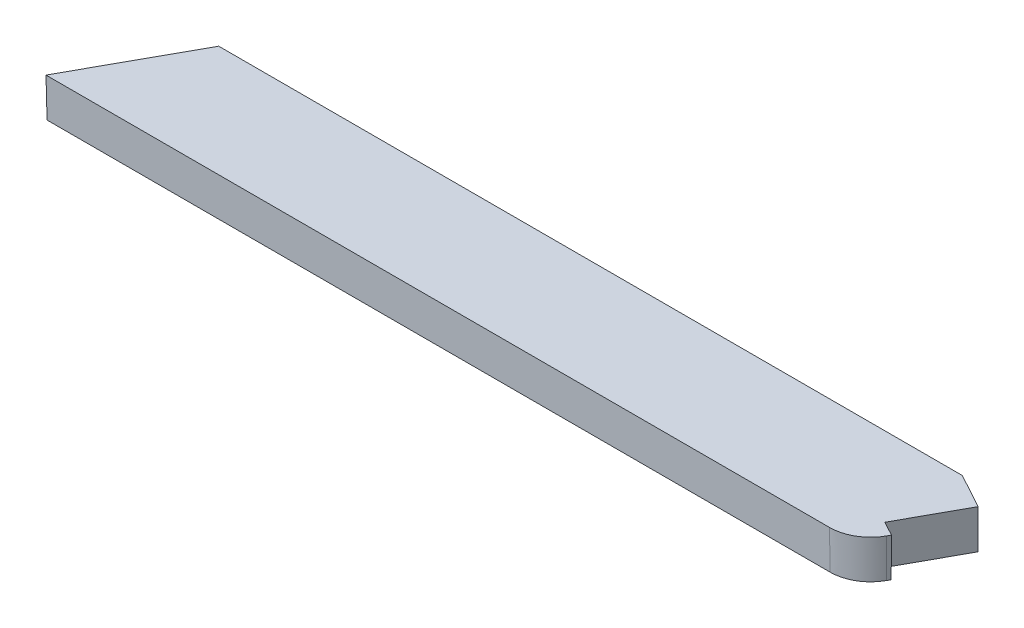
from build123d import *

# Parameters (mm, degrees)
BOSS_EXTRUDE1_DEPTH = 5
CUT_EXTRUDE1_REACH  = 114.056
CUT_EXTRUDE2_REACH  = 111.68
FILLET1_R           = 5.25
DRAFT1_ANGLE        = -1


with BuildPart() as part:
    # Sketch1 → Boss-Extrude1 (new body)
    with BuildSketch(Plane(origin=(0, 0, 0), x_dir=(1, 0, 0), z_dir=(0, 1, 0))):
        Polygon((0, 0), (7.835950564, 14.23), (111.035815461, 14.23), (103.199864898, 0), align=None)
    extrude(amount=BOSS_EXTRUDE1_DEPTH)

    # Sketch2 → Cut-Extrude1 (cut, up to next)
    with BuildSketch(Plane(origin=(0, 5, 0), x_dir=(1, 0, 0), z_dir=(0, 1, 0)), mode=Mode.PRIVATE) as cut_extrude1_sk1:
        Polygon((104.909775718, 3.105179235), (103.070238426, 4.118146436), (108.638473467, 14.23), (111.035815461, 14.23), align=None)
    cut_extrude1_tool1 = extrude(cut_extrude1_sk1.sketch, amount=-CUT_EXTRUDE1_REACH, mode=Mode.PRIVATE) & part.part
    add(cut_extrude1_tool1.solids().sort_by_distance((106.930417, 5, -8.916805))[0], mode=Mode.SUBTRACT)

    # Sketch4 → Cut-Extrude2 (cut, up to next)
    with BuildSketch(Plane(origin=(0, 5, 0), x_dir=(1, 0, 0), z_dir=(0, 1, 0)), mode=Mode.PRIVATE) as cut_extrude2_sk1:
        Polygon((108.638473467, 14.23), (107.2909351, 11.782885153), (102.847001464, 14.23), align=None)
    cut_extrude2_tool1 = extrude(cut_extrude2_sk1.sketch, amount=-CUT_EXTRUDE2_REACH, mode=Mode.PRIVATE) & part.part
    add(cut_extrude2_tool1.solids().sort_by_distance((106.258803, 5, -13.414295))[0], mode=Mode.SUBTRACT)

    # Fillet1
    fillet1_edges = [part.edges().sort_by_distance(p)[0] for p in [
        (103.199864898, 2.5, 0),
    ]]
    fillet(fillet1_edges, radius=FILLET1_R)

    # Draft1
    draft1_faces = [part.faces().sort_by_distance(p)[0] for p in [
        (50.048748296, 2.5, 0),
        (104.80305777, 2.5, -2.911380615),
        (102.76838647, 2.5, -0.730171766),
    ]]
    draft(draft1_faces, Plane.ZX.offset(5), DRAFT1_ANGLE)


solid = part.part
